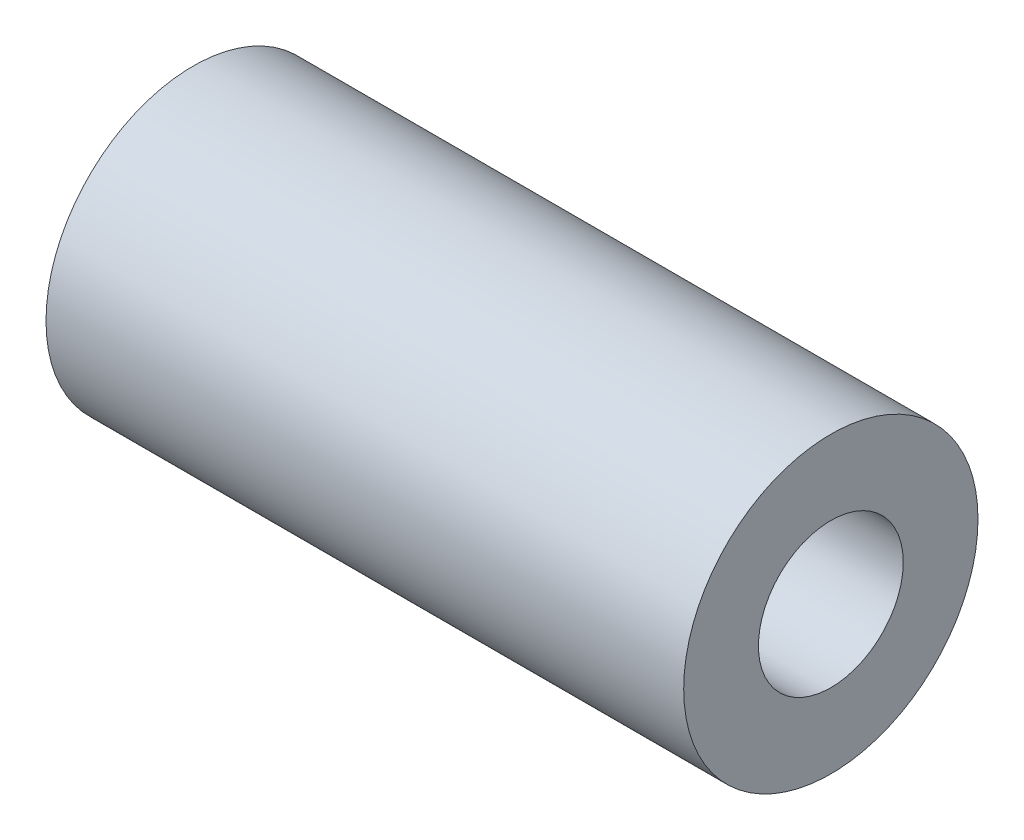
from build123d import *

# Parameters (mm, degrees)
SKETCH1_R           = 3.81
SKETCH1_R_2         = 1.875
BOSS_EXTRUDE1_DEPTH = 16.51


with BuildPart() as part:
    # Sketch1 → Boss-Extrude1 (new body)
    with BuildSketch(Plane(origin=(0, 0, 0), x_dir=(0, 0, -1), z_dir=(1, 0, 0))):
        Circle(SKETCH1_R)
        Circle(SKETCH1_R_2, mode=Mode.SUBTRACT)
    extrude(amount=BOSS_EXTRUDE1_DEPTH)


solid = part.part
